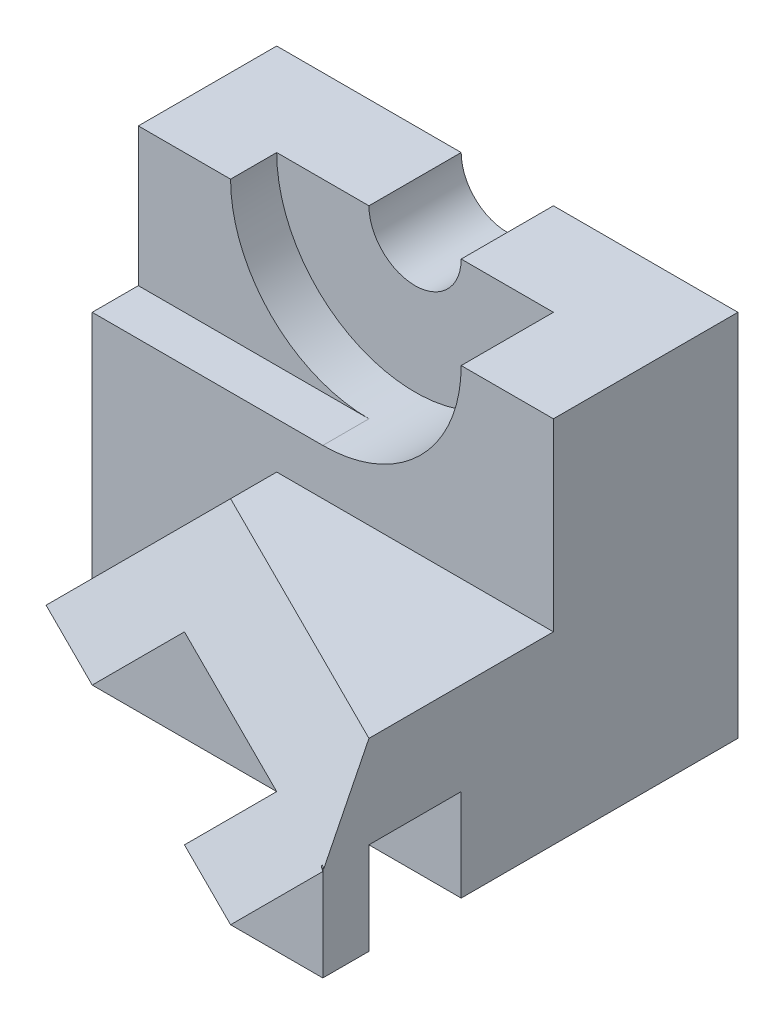
from build123d import *

# Parameters (mm, degrees)
SKETCH1_W            = 100
SKETCH1_H            = 80
BOSS_EXTRUDE1_DEPTH  = 90
CUT_EXTRUDE1_DEPTH   = 90
SKETCH4_W            = 20
SKETCH4_H            = 20
CUT_EXTRUDE2_DEPTH   = 90
CUT_EXTRUDE3_DEPTH   = 90
CUT_EXTRUDE4_DEPTH   = 90
SKETCH7_W            = 100
SKETCH7_H            = 40
CUT_EXTRUDE5_DEPTH   = 90
CUT_EXTRUDE6_DEPTH   = 10
CUT_EXTRUDE7_DEPTH   = 94
SKETCH10_W           = 100
SKETCH10_H           = 50
CUT_EXTRUDE8_DEPTH   = 94
BOSS_EXTRUDE2_DEPTH  = 40
BOSS_EXTRUDE4_DEPTH  = 10
BOSS_EXTRUDE5_DEPTH  = 10
BOSS_EXTRUDE9_DEPTH  = 10
SKETCH22_W           = 13.645756347
SKETCH22_H           = 19.751560391
CUT_EXTRUDE12_DEPTH  = 57
BOSS_EXTRUDE13_DEPTH = 20
BOSS_EXTRUDE14_DEPTH = 20
SKETCH25_W           = 10
SKETCH25_H           = 20
BOSS_EXTRUDE16_DEPTH = 40
CUT_EXTRUDE13_DEPTH  = 40
CUT_EXTRUDE14_DEPTH  = 40
CUT_EXTRUDE15_DEPTH  = 40
CUT_EXTRUDE16_DEPTH  = 40
SKETCH30_W           = 20
SKETCH30_H           = 19.999
CUT_EXTRUDE18_DEPTH  = 125
BOSS_EXTRUDE25_DEPTH = 0.5
CUT_EXTRUDE21_DEPTH  = 0.5
CUT_EXTRUDE22_DEPTH  = 2.5
SKETCH36_W           = 1.148729496
SKETCH36_H           = 4.006964713
BOSS_EXTRUDE26_DEPTH = 2.5
CUT_EXTRUDE23_DEPTH  = 2.5
CUT_EXTRUDE24_DEPTH  = 2.5
SKETCH40_W           = 100
SKETCH40_H           = 60
CUT_EXTRUDE25_DEPTH  = 39.5
BOSS_EXTRUDE31_DEPTH = 80
SKETCH45_W           = 90
SKETCH45_H           = 80
CUT_EXTRUDE27_DEPTH  = 80
SKETCH46_W           = 100
SKETCH46_H           = 50
CUT_EXTRUDE28_DEPTH  = 80
CUT_EXTRUDE29_DEPTH  = 80
CUT_EXTRUDE30_DEPTH  = 80
CUT_EXTRUDE32_DEPTH  = 80
SKETCH51_W           = 25.130664003
SKETCH51_H           = 300
CUT_EXTRUDE33_DEPTH  = 80
SKETCH52_W           = 100
SKETCH52_H           = 80
CUT_EXTRUDE34_DEPTH  = 80
CUT_EXTRUDE35_DEPTH  = 80
CUT_EXTRUDE36_DEPTH  = 80
CUT_EXTRUDE37_DEPTH  = 80
SKETCH56_W           = 16.617380904
SKETCH56_H           = 14.273809877
CUT_EXTRUDE38_DEPTH  = 80
SKETCH57_W           = 100.195151688
SKETCH57_H           = 57.157925485
CUT_EXTRUDE39_DEPTH  = 80
SKETCH58_W           = 20
SKETCH58_H           = 20
CUT_EXTRUDE40_DEPTH  = 80


with BuildPart() as part:
    # Sketch1 → Boss-Extrude1 (new body)
    with BuildSketch(Plane.XY):
        with Locations((50, 40)):
            Rectangle(SKETCH1_W, SKETCH1_H)
    extrude(amount=BOSS_EXTRUDE1_DEPTH)

    # Sketch3 → Cut-Extrude1 (cut)
    with BuildSketch(Plane(origin=(0, 80, 0), x_dir=(1, 0, 0), z_dir=(0, 1, 0))):
        Polygon((0, -50), (20, -60), (40, -60), (80, -80), (60, -80), (80, -90), (0, -90), align=None)
    extrude(amount=-CUT_EXTRUDE1_DEPTH, mode=Mode.SUBTRACT)

    # Sketch4 → Cut-Extrude2 (cut)
    with BuildSketch(Plane(origin=(100, 0, 0), x_dir=(0, 0, -1), z_dir=(1, 0, 0))):
        with Locations((-70, 10)):
            Rectangle(SKETCH4_W, SKETCH4_H)
    extrude(amount=-CUT_EXTRUDE2_DEPTH, mode=Mode.SUBTRACT)

    # Sketch5 → Cut-Extrude3 (cut)
    with BuildSketch(Plane(origin=(0, 0, 0), x_dir=(-1, 0, 0), z_dir=(0, 0, -1))):
        with BuildLine():
            Line((-60, 80), (-40, 80))
            ThreePointArc((-40, 80), (-50, 70), (-60, 80))
        make_face()
    extrude(amount=-CUT_EXTRUDE3_DEPTH, mode=Mode.SUBTRACT)

    # Sketch6 → Cut-Extrude4 (cut)
    with BuildSketch(Plane.XY.offset(20)):
        with BuildLine():
            Line((20, 80), (80, 80))
            ThreePointArc((80, 80), (50, 50), (20, 80))
        make_face()
    extrude(amount=CUT_EXTRUDE4_DEPTH, mode=Mode.SUBTRACT)

    # Sketch7 → Cut-Extrude5 (cut)
    with BuildSketch(Plane.XY.offset(40)):
        with Locations((50, 60)):
            Rectangle(SKETCH7_W, SKETCH7_H)
    extrude(amount=CUT_EXTRUDE5_DEPTH, mode=Mode.SUBTRACT)

    # Sketch8 → Cut-Extrude6 (cut)
    with BuildSketch(Plane.XY.offset(40)):
        with BuildLine():
            Line((50, 50), (0, 50))
            Line((0, 50), (0, 80))
            Line((0, 80), (20, 80))
            ThreePointArc((20, 80), (28.786796564, 58.786796564), (50, 50))
        make_face()
    extrude(amount=-CUT_EXTRUDE6_DEPTH, mode=Mode.SUBTRACT)

    # Sketch9 → Cut-Extrude7 (cut)
    with BuildSketch(Plane.XY.offset(40)):
        Polygon((40, 40), (0, 0), (0, 40), align=None)
    extrude(amount=CUT_EXTRUDE7_DEPTH, mode=Mode.SUBTRACT)

    # Sketch10 → Cut-Extrude8 (cut)
    with BuildSketch(Plane.XY.offset(50)):
        with Locations((50, 25)):
            Rectangle(SKETCH10_W, SKETCH10_H)
    extrude(amount=CUT_EXTRUDE8_DEPTH, mode=Mode.SUBTRACT)

    # Sketch11 → Boss-Extrude2 (add)
    with BuildSketch(Plane(origin=(0, 40, 0), x_dir=(1, 0, 0), z_dir=(0, 1, 0))):
        Polygon((100, -50), (100, -80), (40, -50), align=None)
    extrude(amount=-BOSS_EXTRUDE2_DEPTH)

    # Sketch15 → Boss-Extrude4 (add)
    with BuildSketch(Plane.XY.offset(50)):
        Polygon((20, 0), (40, 20), (100, 20), (100, 0), (40, 0), align=None)
    extrude(amount=BOSS_EXTRUDE4_DEPTH)

    # Sketch16 → Boss-Extrude5 (add)
    with BuildSketch(Plane(origin=(-16.666666667, 16.666666667, 33.333333333), x_dir=(-0.912870929, -0.182574186, -0.365148372), z_dir=(0.40824829, -0.40824829, -0.816496581))):
        Polygon((-62.075223184, -8.94427191), (-42.075223184, -2.913523754), (-18.257418584, -22.360679775), (-40.166320884, -26.83281573), align=None)
    extrude(amount=BOSS_EXTRUDE5_DEPTH)

    # Sketch18 → Boss-Extrude9 (add)
    with BuildSketch(Plane(origin=(0, 20, 0), x_dir=(1, 0, 0), z_dir=(0, 1, 0))):
        Polygon((40, -50), (40, -60), (21.742581416, -50), align=None)
    extrude(amount=-BOSS_EXTRUDE9_DEPTH)

    # Sketch22 → Cut-Extrude12 (cut)
    with BuildSketch(Plane(origin=(40, 0, 0), x_dir=(0, 0, -1), z_dir=(1, 0, 0))):
        with Locations((-56.822878174, 29.875780196)):
            Rectangle(SKETCH22_W, SKETCH22_H)
    extrude(amount=-CUT_EXTRUDE12_DEPTH, mode=Mode.SUBTRACT)

    # Sketch23 → Boss-Extrude13 (add)
    with BuildSketch(Plane(origin=(0, 20, 0), x_dir=(1, 0, 0), z_dir=(0, 1, 0))):
        Polygon((20, -50), (100, -90), (40, -50), align=None)
    extrude(amount=-BOSS_EXTRUDE13_DEPTH)

    # Sketch24 → Boss-Extrude14 (add)
    with BuildSketch(Plane(origin=(0, 20, 0), x_dir=(1, 0, 0), z_dir=(0, 1, 0))):
        Polygon((100, -90), (100, -80), (60, -60), (55, -60), align=None)
    extrude(amount=-BOSS_EXTRUDE14_DEPTH)

    # Sketch25 → Boss-Extrude16 (add)
    with BuildSketch(Plane(origin=(100, 0, 0), x_dir=(0, 0, -1), z_dir=(1, 0, 0))):
        with Locations((-85, 10)):
            Rectangle(SKETCH25_W, SKETCH25_H)
    extrude(amount=-BOSS_EXTRUDE16_DEPTH)

    # Sketch26 → Cut-Extrude13 (cut)
    with BuildSketch(Plane(origin=(-16.666666667, 16.666666667, 33.333333333), x_dir=(0.912870929, 0.182574186, 0.365148372), z_dir=(-0.40824829, 0.40824829, 0.816496581))):
        Polygon((105.893027784, -17.88854382), (83.984125484, -35.77708764), (105.893027784, -40.249223595), align=None)
    extrude(amount=CUT_EXTRUDE13_DEPTH, mode=Mode.SUBTRACT)

    # Sketch27 → Cut-Extrude14 (cut)
    with BuildSketch(Plane(origin=(-3.333333333, -16.666666667, 6.666666667), x_dir=(0.98319208, -0.169515876, 0.06780635), z_dir=(0.182574186, 0.912870929, -0.365148372))):
        Polygon((64.416032844, -74.278135271), (84.757937953, -83.56290218), (64.416032844, -85.048464885), align=None)
    extrude(amount=-CUT_EXTRUDE14_DEPTH, mode=Mode.SUBTRACT)

    # Sketch28 → Cut-Extrude15 (cut)
    with BuildSketch(Plane(origin=(0, 0, 80), x_dir=(-1, 0, 0), z_dir=(0, 0, -1))):
        Polygon((-80, 20), (-60, 0), (-60, 20), align=None)
    extrude(amount=-CUT_EXTRUDE15_DEPTH, mode=Mode.SUBTRACT)

    # Sketch29 → Cut-Extrude16 (cut)
    with BuildSketch(Plane(origin=(-16.666666667, 16.666666667, 33.333333333), x_dir=(-0.912870929, -0.182574186, -0.365148372), z_dir=(0.40824829, -0.40824829, -0.816496581))):
        Polygon((-105.893027784, -17.88854382), (-105.893027784, -40.249223595), (-127.801930085, -22.360679775), align=None)
    extrude(amount=-CUT_EXTRUDE16_DEPTH, mode=Mode.SUBTRACT)

    # Sketch30 → Cut-Extrude18 (cut)
    with BuildSketch(Plane(origin=(100, 0, 0), x_dir=(0, 0, -1), z_dir=(1, 0, 0))):
        with Locations((-70, 9.9995)):
            Rectangle(SKETCH30_W, SKETCH30_H)
    extrude(amount=-CUT_EXTRUDE18_DEPTH, mode=Mode.SUBTRACT)

    # Sketch31 → Boss-Extrude25 (add)
    with BuildSketch(Plane(origin=(0, 20, 0), x_dir=(1, 0, 0), z_dir=(0, 1, 0))):
        Polygon((40, -50), (20, -50), (100, -90), (100, -80), align=None)
    extrude(amount=BOSS_EXTRUDE25_DEPTH)

    # Sketch34 → Cut-Extrude21 (cut)
    with BuildSketch(Plane(origin=(-16.666666667, 16.666666667, 33.333333333), x_dir=(0.912870929, 0.182574186, 0.365148372), z_dir=(-0.40824829, 0.40824829, 0.816496581))):
        Polygon((40.166320884, -4.472135955), (127.801930085, -22.360679775), (94.938576634, 6.708203932), align=None)
    extrude(amount=CUT_EXTRUDE21_DEPTH, mode=Mode.SUBTRACT)

    # Sketch35 → Cut-Extrude22 (cut)
    with BuildSketch(Plane(origin=(2.266666667, -10.426666667, 6.346666667), x_dir=(0.98319208, 0.155954606, -0.094928891), z_dir=(0.182574186, -0.839841255, 0.51120772))):
        Polygon((19.011205483, 53.778143667), (19.307858266, 53.68916465), (18.036489196, 53.108866719), align=None)
    extrude(amount=-CUT_EXTRUDE22_DEPTH, mode=Mode.SUBTRACT)

    # Sketch36 → Boss-Extrude26 (add)
    with BuildSketch(Plane(origin=(0, 0, 0), x_dir=(0, 0, 1), z_dir=(-0.707106781, 0.707106781, 0))):
        with Locations((49.425635252, 29.062065395)):
            Rectangle(SKETCH36_W, SKETCH36_H)
    extrude(amount=-BOSS_EXTRUDE26_DEPTH)

    # Sketch37 → Cut-Extrude23 (cut)
    with BuildSketch(Plane(origin=(0, 0, 50), x_dir=(-1, 0, 0), z_dir=(0, 0, -1))):
        Polygon((-20, 20), (-20.305780347, 20.5), (-20, 20.5), align=None)
    extrude(amount=-CUT_EXTRUDE23_DEPTH, mode=Mode.SUBTRACT)

    # Sketch39 → Cut-Extrude24 (cut)
    with BuildSketch(Plane(origin=(-18.683928387, 11.426356204, 25.444702473), x_dir=(-0.830826199, -0.22798675, -0.507690722), z_dir=(0.556531965, -0.340353074, -0.757912895))):
        Polygon((-46.928838789, -1.781888159), (-47.714265377, -1.978181738), (-46.56079509, -2.238008161), align=None)
    extrude(amount=-CUT_EXTRUDE24_DEPTH, mode=Mode.SUBTRACT)

    # Sketch40 → Cut-Extrude25 (cut)
    with BuildSketch(Plane.XZ):
        with Locations((50, 30)):
            Rectangle(SKETCH40_W, SKETCH40_H)
    extrude(amount=CUT_EXTRUDE25_DEPTH, mode=Mode.SUBTRACT)

    # Sketch41 → Boss-Extrude31 (add)
    with BuildSketch(Plane(origin=(-16.666666667, 16.666666667, 33.333333333), x_dir=(0.912870929, 0.182574186, 0.365148372), z_dir=(-0.40824829, 0.40824829, 0.816496581))):
        Polygon((40.166320884, -4.472135955), (62.075223184, 13.416407865), (127.801930085, 0), (127.801930085, -22.360679775), align=None)
    extrude(amount=-BOSS_EXTRUDE31_DEPTH)

    # Sketch45 → Cut-Extrude27 (cut)
    with BuildSketch(Plane(origin=(100, 0, 0), x_dir=(0, 0, -1), z_dir=(1, 0, 0))):
        with Locations((-45, 40)):
            Rectangle(SKETCH45_W, SKETCH45_H)
    extrude(amount=CUT_EXTRUDE27_DEPTH, mode=Mode.SUBTRACT)

    # Sketch46 → Cut-Extrude28 (cut)
    with BuildSketch(Plane.XZ):
        with Locations((50, 25)):
            Rectangle(SKETCH46_W, SKETCH46_H)
    extrude(amount=CUT_EXTRUDE28_DEPTH, mode=Mode.SUBTRACT)

    # Sketch47 → Cut-Extrude29 (cut)
    with BuildSketch(Plane(origin=(0, 0, 0), x_dir=(1, 0, 0), z_dir=(0, 1, 0))):
        Polygon((120, -50), (100, -40), (100, -2.020410289), (132.659863237, -18.350341907), align=None)
    extrude(amount=-CUT_EXTRUDE29_DEPTH, mode=Mode.SUBTRACT)

    # Sketch48 → Cut-Extrude30 (cut)
    with BuildSketch(Plane(origin=(120.689655172, 0, 48.275862069), x_dir=(-0.371390676, 0, 0.928476691), z_dir=(-0.928476691, 0, -0.371390676))):
        Polygon((-32.230771602, 0), (1.856953382, 0), (-26.549484105, -12.659863237), align=None)
    extrude(amount=-CUT_EXTRUDE30_DEPTH, mode=Mode.SUBTRACT)

    # Sketch49 → Cut-Extrude32 (cut)
    with BuildSketch(Plane(origin=(-0.114281179, -0.690448792, 0.285702948), x_dir=(0.988505824, -0.139695442, 0.057805011), z_dir=(0.15118279, 0.91339602, -0.377956974))):
        Polygon((134.318019367, -17.958704237), (121.510949414, -46.200841621), (131.829451772, -17.958704237), (119.414758754, -17.958704237), (119.414758754, -48.439344206), (134.318019367, -48.439344206), align=None)
    extrude(amount=-CUT_EXTRUDE32_DEPTH, mode=Mode.SUBTRACT)

    # Sketch51 → Cut-Extrude33 (cut)
    with BuildSketch(Plane(origin=(0.666666667, 3.333333333, -1.333333333), x_dir=(-0.98319208, 0.169515876, -0.06780635), z_dir=(-0.182574186, -0.912870929, 0.365148372))):
        with Locations((-131.048534724, 103.044069574)):
            Rectangle(SKETCH51_W, SKETCH51_H)
    extrude(amount=-CUT_EXTRUDE33_DEPTH, mode=Mode.SUBTRACT)

    # Sketch52 → Cut-Extrude34 (cut)
    with BuildSketch(Plane(origin=(0, 0, 0), x_dir=(-1, 0, 0), z_dir=(0, 0, -1))):
        with Locations((-50, 40)):
            Rectangle(SKETCH52_W, SKETCH52_H)
    extrude(amount=CUT_EXTRUDE34_DEPTH, mode=Mode.SUBTRACT)

    # Sketch53 → Cut-Extrude35 (cut)
    with BuildSketch(Plane.XY):
        Polygon((100, 8), (100, 4.040820577), (103.299316186, 7.340136763), align=None)
    extrude(amount=-CUT_EXTRUDE35_DEPTH, mode=Mode.SUBTRACT)

    # Sketch54 → Cut-Extrude36 (cut)
    with BuildSketch(Plane(origin=(0, 0, 0), x_dir=(1, 0, 0), z_dir=(0, 1, 0))):
        Polygon((50, 0), (95.959179423, 0), (65.319726474, 15.319726474), align=None)
    extrude(amount=-CUT_EXTRUDE36_DEPTH, mode=Mode.SUBTRACT)

    # Sketch55 → Cut-Extrude37 (cut)
    with BuildSketch(Plane(origin=(25, 0, 25), x_dir=(0.707106781, 0, -0.707106781), z_dir=(0.707106781, 0, 0.707106781))):
        Polygon((35.355339059, 0), (35.355339059, -6), (51.052787248, -12.659863237), (57.020704011, 0), align=None)
    extrude(amount=-CUT_EXTRUDE37_DEPTH, mode=Mode.SUBTRACT)

    # Sketch56 → Cut-Extrude38 (cut)
    with BuildSketch(Plane(origin=(2.288135593, 7.627118644, -2.288135593), x_dir=(0.961108118, -0.26452517, 0.079357551), z_dir=(0.276172385, 0.920574618, -0.276172385))):
        with Locations((54.829850342, 11.734471108)):
            Rectangle(SKETCH56_W, SKETCH56_H)
    extrude(amount=-CUT_EXTRUDE38_DEPTH, mode=Mode.SUBTRACT)

    # Sketch57 → Cut-Extrude39 (cut)
    with BuildSketch(Plane(origin=(0, 0, 0), x_dir=(-1, 0, 0), z_dir=(0, 0, -1))):
        with Locations((-50.097575844, -14.861233679)):
            Rectangle(SKETCH57_W, SKETCH57_H)
    extrude(amount=CUT_EXTRUDE39_DEPTH, mode=Mode.SUBTRACT)

    # Sketch58 → Cut-Extrude40 (cut)
    with BuildSketch(Plane(origin=(100, 0, 0), x_dir=(0, 0, -1), z_dir=(1, 0, 0))):
        with Locations((-70, 10)):
            Rectangle(SKETCH58_W, SKETCH58_H)
    extrude(amount=-CUT_EXTRUDE40_DEPTH, mode=Mode.SUBTRACT)


solid = part.part
